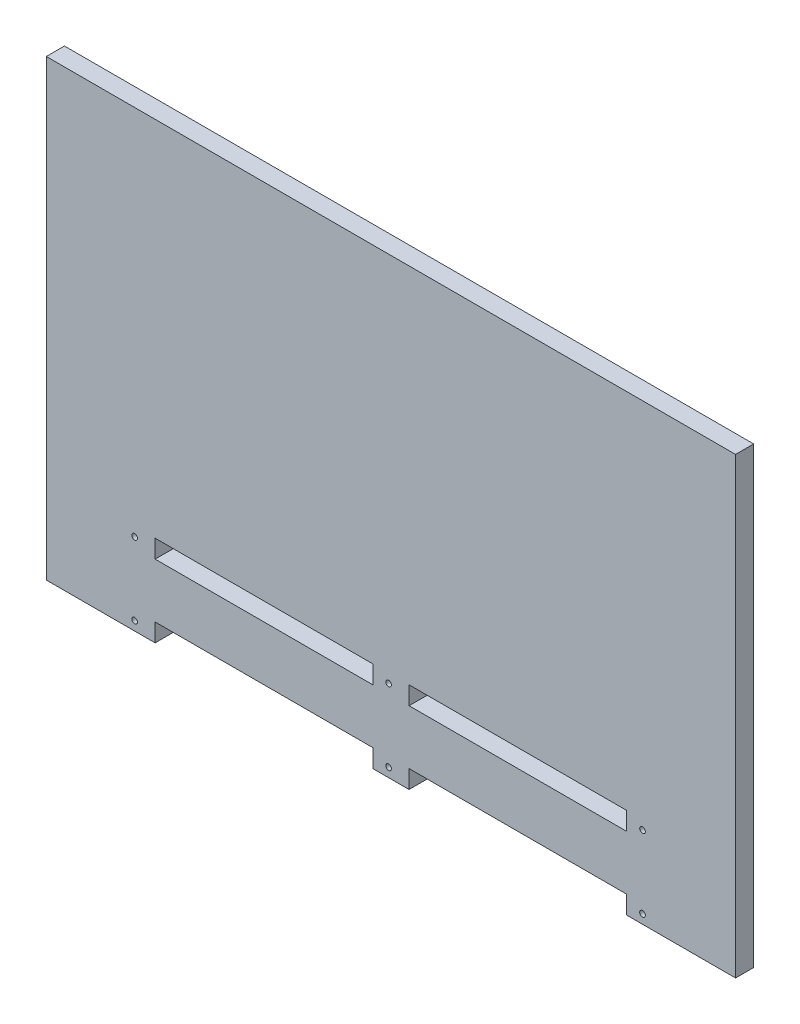
from build123d import *

# Parameters (mm, degrees)
IZIM1_R             = 1.55
IZIM1_W             = 120
IZIM1_H             = 10
BOSS_EXTRUDE2_DEPTH = 10


with BuildPart() as part:
    # Çizim1 → Boss-Extrude2 (new body)
    with BuildSketch(Plane.XY):
        Polygon((-130, -250), (-130, -240), (-10, -240), (-10, -250), (10, -250), (10, -240), (130, -240), (130, -250), (190, -250), (190, 0), (-190, 0), (-190, -250), align=None)
        with Locations((-141.295330694, -245)):
            Circle(IZIM1_R, mode=Mode.SUBTRACT)
        with Locations((-141.295330694, -205)):
            Circle(IZIM1_R, mode=Mode.SUBTRACT)
        with Locations((-70, -205)):
            Rectangle(IZIM1_W, IZIM1_H, mode=Mode.SUBTRACT)
        with Locations((-1.295330694, -245)):
            Circle(IZIM1_R, mode=Mode.SUBTRACT)
        with Locations((-1.295330694, -205)):
            Circle(IZIM1_R, mode=Mode.SUBTRACT)
        with Locations((70, -205)):
            Rectangle(IZIM1_W, IZIM1_H, mode=Mode.SUBTRACT)
        with Locations((138.704669306, -245)):
            Circle(IZIM1_R, mode=Mode.SUBTRACT)
        with Locations((138.704669306, -205)):
            Circle(IZIM1_R, mode=Mode.SUBTRACT)
    extrude(amount=BOSS_EXTRUDE2_DEPTH)


solid = part.part
